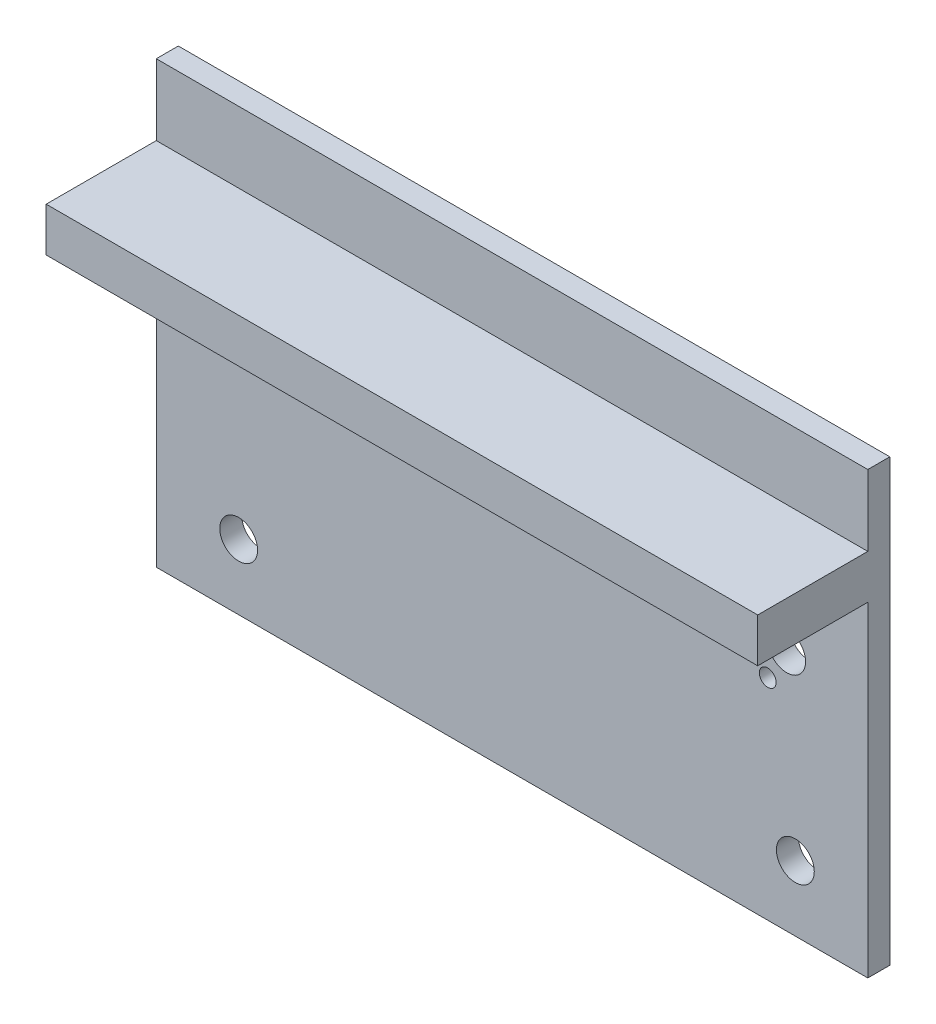
from build123d import *

# Parameters (mm, degrees)
ESQUISSE14_W       = 64.629945491
ESQUISSE14_H       = 40
ESQUISSE14_R       = 1.719219897
ESQUISSE14_R_2     = 0.762879998
BOSS_EXTRU_1_DEPTH = 2
ESQUISSE15_W       = 64.629945491
ESQUISSE15_H       = 4
BOSS_EXTRU_2_DEPTH = 10


with BuildPart() as part:
    # Esquisse14 → Boss.-Extru.1 (new body)
    with BuildSketch(Plane.XY):
        with Locations((-35.198967366, -21.902230173)):
            Rectangle(ESQUISSE14_W, ESQUISSE14_H)
        with Locations((-10.253804476, -19.851102207)):
            Circle(ESQUISSE14_R, mode=Mode.SUBTRACT)
        with Locations((-9.464985935, -35.965799335)):
            Circle(ESQUISSE14_R, mode=Mode.SUBTRACT)
        with Locations((-58.998745092, -18.695161475)):
            Circle(ESQUISSE14_R, mode=Mode.SUBTRACT)
        with Locations((-60.03027703, -35.965799335)):
            Circle(ESQUISSE14_R, mode=Mode.SUBTRACT)
        with Locations((-11.973024373, -22.81882365)):
            Circle(ESQUISSE14_R_2, mode=Mode.SUBTRACT)
    extrude(amount=-BOSS_EXTRU_1_DEPTH)

    # Esquisse15 → Boss.-Extru.2 (add)
    with BuildSketch(Plane.XY):
        with Locations((-35.198967366, -10.343644154)):
            Rectangle(ESQUISSE15_W, ESQUISSE15_H)
    extrude(amount=BOSS_EXTRU_2_DEPTH)


solid = part.part
